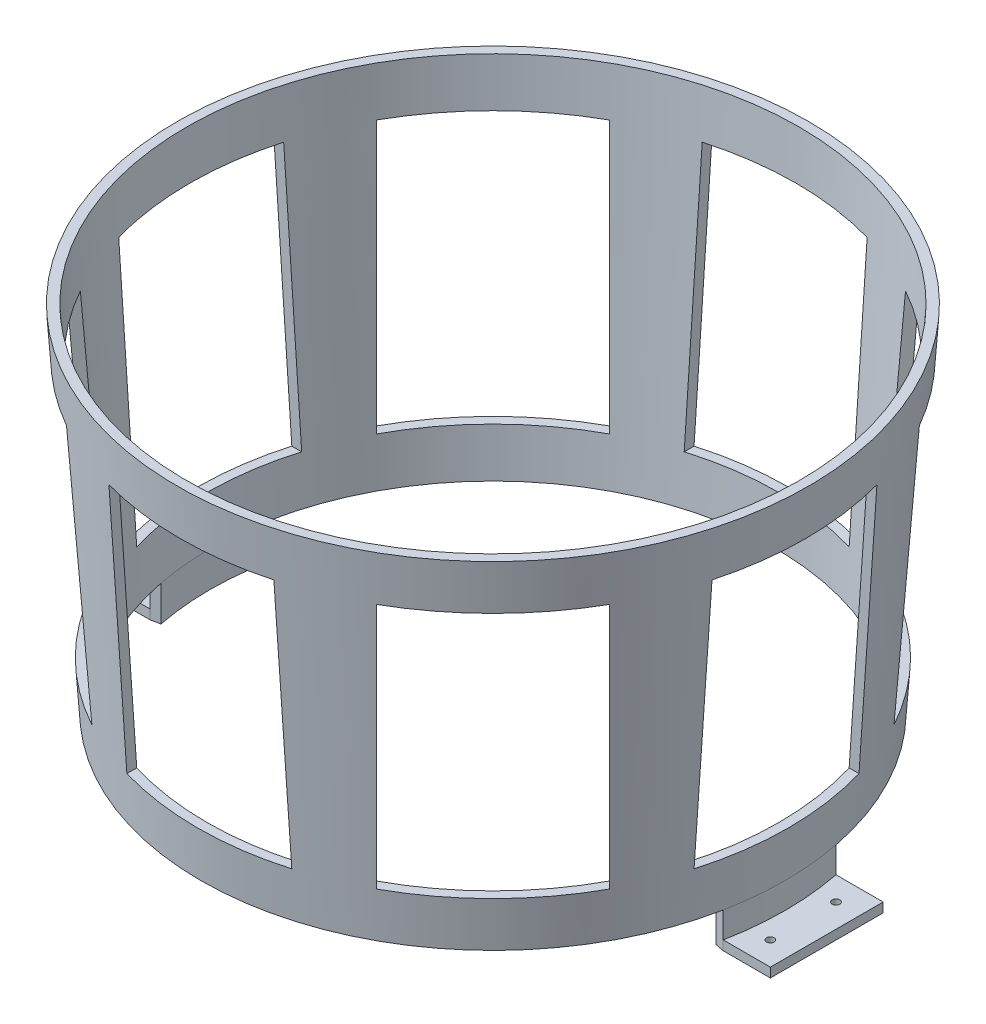
from build123d import *

# Parameters (mm, degrees)
SKETCH6_W           = 70
SKETCH6_H           = 110
CUT_EXTRUDE2_DEPTH  = 20
BOSS_EXTRUDE1_DEPTH = 15
BOSS_EXTRUDE2_DEPTH = 4
SKETCH9_R           = 1.6
CUT_EXTRUDE3_DEPTH  = 24
CIRPATTERN1_COUNT   = 8


with BuildPart() as part:
    # Sketch2 → Revolve1 (revolve)
    with BuildSketch(Plane.XY):
        Polygon((120, 0), (130, 150), (134.008879034, 150), (124.008879034, 0), align=None)
    revolve(axis=Axis((0, 0, 0), (0, 1, 0)))

    # Sketch6 → Cut-Extrude2 (cut, symmetric)
    with BuildSketch(Plane.XY.offset(134)):
        with Locations((0, 75)):
            Rectangle(SKETCH6_W, SKETCH6_H)
    cut_extrude2 = extrude(amount=CUT_EXTRUDE2_DEPTH, both=True, mode=Mode.SUBTRACT)

    # Sketch7 → Boss-Extrude1 (add)
    with BuildSketch(Plane(origin=(0, 0, 0), x_dir=(1, 0, 0), z_dir=(0, 1, 0))):
        with BuildLine():
            Line((-117.744298431, 23.157724131), (-121.677820509, 23.931361754))
            ThreePointArc((-121.677820509, 23.931361754), (-124.008879034, 0), (-121.677820509, -23.931361754))
            Line((-121.677820509, -23.931361754), (-117.744298431, -23.157724131))
            ThreePointArc((-117.744298431, -23.157724131), (-120, 0), (-117.744298431, 23.157724131))
        make_face()
        with BuildLine():
            Line((117.744298431, -23.157724131), (121.677820509, -23.931361754))
            ThreePointArc((121.677820509, -23.931361754), (124.008879034, 0), (121.677820509, 23.931361754))
            Line((121.677820509, 23.931361754), (117.744298431, 23.157724131))
            ThreePointArc((117.744298431, 23.157724131), (120, 0), (117.744298431, -23.157724131))
        make_face()
    extrude(amount=-BOSS_EXTRUDE1_DEPTH)

    # Sketch8 → Boss-Extrude2 (add)
    with BuildSketch(Plane.XZ.offset(15)):
        with BuildLine():
            Line((121.677820509, 23.931361754), (141.677820509, 23.931361754))
            Line((141.677820509, 23.931361754), (141.677820509, -23.931361754))
            Line((141.677820509, -23.931361754), (121.677820509, -23.931361754))
            ThreePointArc((121.677820509, -23.931361754), (124.008879034, 0), (121.677820509, 23.931361754))
        make_face()
        with BuildLine():
            Line((-121.677820509, 23.931361754), (-141.677820509, 23.931361754))
            Line((-141.677820509, 23.931361754), (-141.677820509, -23.931361754))
            Line((-141.677820509, -23.931361754), (-121.677820509, -23.931361754))
            ThreePointArc((-121.677820509, -23.931361754), (-124.008879034, 0), (-121.677820509, 23.931361754))
        make_face()
    extrude(amount=-BOSS_EXTRUDE2_DEPTH)

    # Sketch9 → Cut-Extrude3 (cut)
    with BuildSketch(Plane.XZ.offset(15)):
        with Locations((131.677820509, 13.931361754)):
            Circle(SKETCH9_R)
        with Locations((131.677820509, -13.931361754)):
            Circle(SKETCH9_R)
        with Locations((-131.677820509, -13.931361754)):
            Circle(SKETCH9_R)
        with Locations((-131.677820509, 13.931361754)):
            Circle(SKETCH9_R)
    extrude(amount=-CUT_EXTRUDE3_DEPTH, mode=Mode.SUBTRACT)

    # CirPattern1: Cut-Extrude2 ×8 about axis
    cirpattern1_axis = Axis((0, 0, 0), (0, 1, 0))
    for i in range(1, CIRPATTERN1_COUNT):
        add(cut_extrude2.rotate(cirpattern1_axis, i * 360 / CIRPATTERN1_COUNT), mode=Mode.SUBTRACT)


solid = part.part
